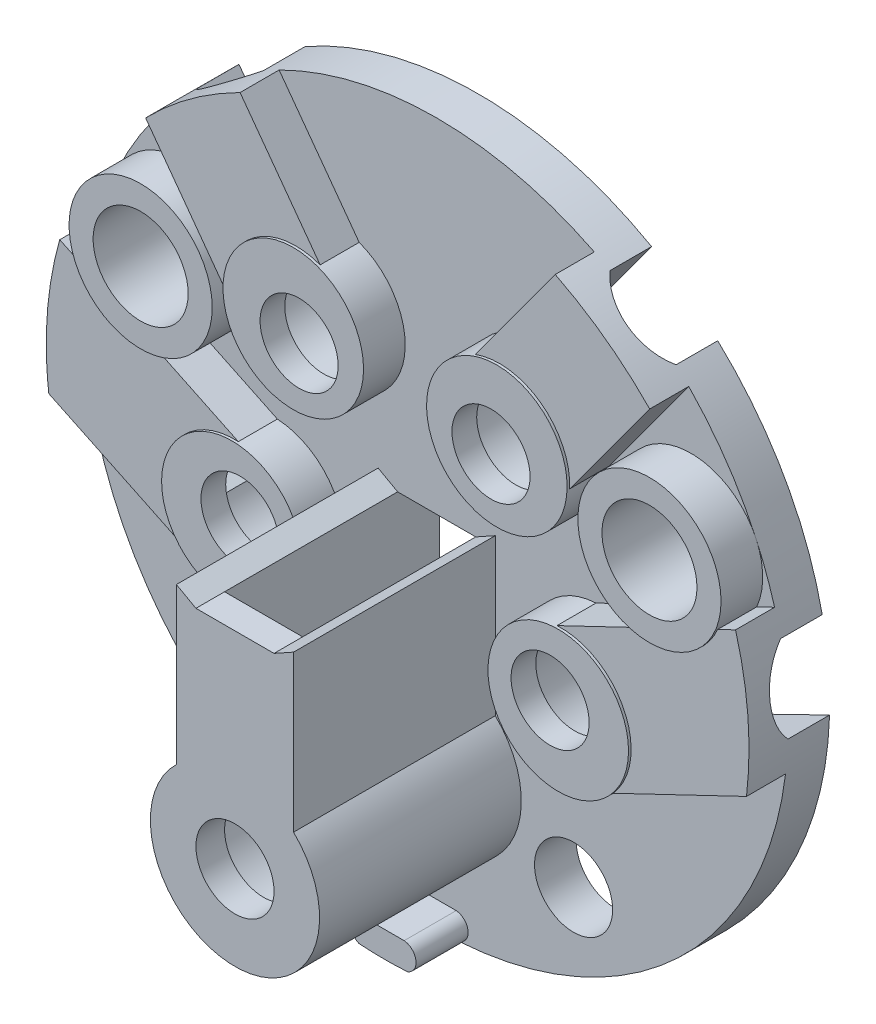
from build123d import *

# Parameters (mm, degrees)
SKETCH1_R           = 27
BOSS_EXTRUDE1_DEPTH = 3.2
BOSS_EXTRUDE2_DEPTH = 3
SKETCH2_4_R         = 5.4
SKETCH2_4_R_2       = 3
SKETCH2_4_R_3       = 3.65
BOSS_EXTRUDE3_DEPTH = 3.2
SKETCH2_5_R         = 3
BOSS_EXTRUDE4_DEPTH = 15.5
BOSS_EXTRUDE5_DEPTH = 4
SKETCH2_7_R         = 3.65
SKETCH2_7_R_2       = 3
CUT_EXTRUDE1_DEPTH  = 4.2
CUT_EXTRUDE2_DEPTH  = 3.2
SKETCH6_R           = 3
SKETCH6_R_2         = 4
CUT_EXTRUDE3_DEPTH  = 4.5
CUT_EXTRUDE4_START  = -14.26605
CUT_EXTRUDE4_DEPTH  = 14.26605
CUT_EXTRUDE5_START  = -11.120277
CUT_EXTRUDE5_DEPTH  = 11.304657
CUT_EXTRUDE6_DEPTH  = 16.5


with BuildPart() as part:
    # Sketch1 → Boss-Extrude1 (new body)
    with BuildSketch(Plane.XY):
        Circle(SKETCH1_R)
    extrude(amount=BOSS_EXTRUDE1_DEPTH)

    # Sketch2 → Boss-Extrude2 (add)
    with BuildSketch(Plane.XY.offset(3.2)):
        with BuildLine():
            Line((13.214734276, 10.418663089), (19.366760675, 18.812989687))
            ThreePointArc((19.366760675, 18.812989687), (15.960385268, 21.777651437), (12.10754353, 24.133118109))
            Line((12.10754353, 24.133118109), (5.95551713, 15.738791512))
            ThreePointArc((5.95551713, 15.738791512), (11.012715775, 15.026647634), (13.214734276, 10.418663089))
        make_face()
        with BuildLine():
            Line((-19.366760675, 18.812989687), (-13.214734276, 10.418663089))
            ThreePointArc((-13.214734276, 10.418663089), (-11.012715775, 15.026647634), (-5.95551713, 15.738791512))
            Line((-5.95551713, 15.738791512), (-12.10754353, 24.133118109))
            ThreePointArc((-12.10754353, 24.133118109), (-15.960385268, 21.777651437), (-19.366760675, 18.812989687))
        make_face()
        with BuildLine():
            Line((-26.803505249, -3.251477571), (-16.556347634, -8.162974501))
            ThreePointArc((-16.556347634, -8.162974501), (-17.408253142, -2.220860702), (-12.242617521, 0.837025499))
            Line((-12.242617521, 0.837025499), (-18.101719949, 3.645312897))
            ThreePointArc((-18.101719949, 3.645312897), (-21.924974658, 3.992090735), (-24.590072646, 6.755202054))
            Line((-24.590072646, 6.755202054), (-25.962429876, 7.412977466))
            ThreePointArc((-25.962429876, 7.412977466), (-26.916419296, 2.122821775), (-26.803505249, -3.251477571))
        make_face()
        with BuildLine():
            Line((16.556347634, -8.162974501), (26.803505249, -3.251477571))
            ThreePointArc((26.803505249, -3.251477571), (26.916419296, 2.122821775), (25.962429876, 7.412977466))
            Line((25.962429876, 7.412977466), (24.590072646, 6.755202054))
            ThreePointArc((24.590072646, 6.755202054), (21.924974658, 3.992090735), (18.101719949, 3.645312897))
            Line((18.101719949, 3.645312897), (12.242617521, 0.837025499))
            ThreePointArc((12.242617521, 0.837025499), (17.408253142, -2.220860702), (16.556347634, -8.162974501))
        make_face()
    extrude(amount=BOSS_EXTRUDE2_DEPTH)

    # Sketch2_4 → Boss-Extrude3 (add)
    with BuildSketch(Plane.XY.offset(3.2)):
        with Locations((-12.538705984, -4.554850949)):
            Circle(SKETCH2_4_R)
        with Locations((-11.912414596, -4.194547939)):
            Circle(SKETCH2_4_R_2, mode=Mode.SUBTRACT)
        with BuildLine():
            ThreePointArc((-24.590072646, 6.755202054), (-21.924974658, 3.992090735), (-18.101719949, 3.645312897))
            ThreePointArc((-18.101719949, 3.645312897), (-15.177222741, 5.612895206), (-14.047762371, 8.951814693))
            ThreePointArc((-14.047762371, 8.951814693), (-20.669656636, 14.336176611), (-24.590072646, 6.755202054))
        make_face()
        with Locations((-19.547762371, 8.951814693)):
            Circle(SKETCH2_4_R_3, mode=Mode.SUBTRACT)
        with Locations((-7.820638721, 10.671117346)):
            Circle(SKETCH2_4_R)
        with Locations((-7.372516546, 9.917200536)):
            Circle(SKETCH2_4_R_2, mode=Mode.SUBTRACT)
        with BuildLine():
            ThreePointArc((5.95551713, 15.738791512), (4.628561668, 6.315587059), (13.214734276, 10.418663089))
            ThreePointArc((13.214734276, 10.418663089), (13.219162408, 10.544855699), (13.220638721, 10.671117346))
            ThreePointArc((13.220638721, 10.671117346), (10.910003009, 15.100093334), (5.95551713, 15.738791512))
        make_face()
        with Locations((7.372516546, 9.917200536)):
            Circle(SKETCH2_4_R_2, mode=Mode.SUBTRACT)
        with BuildLine():
            ThreePointArc((25.047762371, 8.951814693), (16.208842883, 13.322354323), (18.101719949, 3.645312897))
            ThreePointArc((18.101719949, 3.645312897), (21.924974658, 3.992090735), (24.590072646, 6.755202054))
            ThreePointArc((24.590072646, 6.755202054), (24.932124288, 7.829920428), (25.047762371, 8.951814693))
        make_face()
        with Locations((19.547762371, 8.951814693)):
            Circle(SKETCH2_4_R_3, mode=Mode.SUBTRACT)
        with BuildLine():
            ThreePointArc((12.242617521, 0.837025499), (7.669158825, -6.888841195), (16.556347634, -8.162974501))
            ThreePointArc((16.556347634, -8.162974501), (17.581287907, -6.486784577), (17.938705984, -4.554850949))
            ThreePointArc((17.938705984, -4.554850949), (16.250923805, -0.633188183), (12.242617521, 0.837025499))
        make_face()
        with Locations((11.912414596, -4.194547939)):
            Circle(SKETCH2_4_R_2, mode=Mode.SUBTRACT)
    extrude(amount=BOSS_EXTRUDE3_DEPTH)

    # Sketch2_5 → Boss-Extrude4 (add)
    with BuildSketch(Plane.XY.offset(3.2)):
        with BuildLine():
            Line((-4.5, -10.531827265), (-4.5, 1.449233257))
            Line((-4.5, 1.449233257), (-3, 0.615924829))
            Line((-3, 0.615924829), (3, 0.615924829))
            Line((3, 0.615924829), (4.5, 1.449233257))
            Line((4.5, 1.449233257), (4.5, -10.531827265))
            ThreePointArc((4.5, -10.531827265), (0, -21.722243024), (-4.5, -10.531827265))
        make_face()
        with Locations((0, -15.222243024)):
            Circle(SKETCH2_5_R, mode=Mode.SUBTRACT)
    extrude(amount=BOSS_EXTRUDE4_DEPTH)

    # Sketch2_6 → Boss-Extrude5 (add)
    with BuildSketch(Plane.XY.offset(3.2)):
        with BuildLine():
            Line((-1.5, -25), (1.5, -25))
            ThreePointArc((1.5, -25), (2.404652846, -25.869777487), (1.75412196, -26.942959306))
            ThreePointArc((1.75412196, -26.942959306), (-0.110904579, -26.999772224), (-1.975401461, -26.927639872))
            ThreePointArc((-1.975401461, -26.927639872), (-2.565919795, -25.759561579), (-1.5, -25))
        make_face()
    extrude(amount=BOSS_EXTRUDE5_DEPTH)

    # Sketch2_7 → Cut-Extrude1 (cut, through all)
    with BuildSketch(Plane.XY.offset(3.2)):
        with Locations((-19.547762371, 8.951814693)):
            Circle(SKETCH2_7_R)
        with Locations((-11.912414596, -4.194547939)):
            Circle(SKETCH2_7_R_2)
        with Locations((-7.372516546, 9.917200536)):
            Circle(SKETCH2_7_R_2)
        with Locations((7.372516546, 9.917200536)):
            Circle(SKETCH2_7_R_2)
        with Locations((19.547762371, 8.951814693)):
            Circle(SKETCH2_7_R)
        with Locations((11.912414596, -4.194547939)):
            Circle(SKETCH2_7_R_2)
        with Locations((10.5168708, -18.935298149)):
            Circle(SKETCH2_7_R_2)
        with Locations((0, -15.222243024)):
            Circle(SKETCH2_7_R_2)
    extrude(amount=-CUT_EXTRUDE1_DEPTH, mode=Mode.SUBTRACT)

    # Sketch4 → Cut-Extrude2 (cut)
    with BuildSketch(Plane(origin=(0, 0, 0), x_dir=(-1, 0, 0), z_dir=(0, 0, -1))):
        with BuildLine():
            Line((6.737189652, 14.5215898), (15.050415108, 25.864832664))
            Line((15.050415108, 25.864832664), (20.13186711, 22.140742768))
            Line((20.13186711, 22.140742768), (11.818641654, 10.797499904))
            ThreePointArc((11.818641654, 10.797499904), (10.185140243, 13.897436078), (6.737189652, 14.5215898))
        make_face()
        with BuildLine():
            Line((13.60078494, -0.698429254), (28.388304519, 6.51769117))
            Line((28.388304519, 6.51769117), (31.019640476, 1.125467966))
            Line((31.019640476, 1.125467966), (16.232120898, -6.090652457))
            ThreePointArc((16.232120898, -6.090652457), (16.133521453, -2.800626977), (13.60078494, -0.698429254))
        make_face()
    cut_extrude2 = extrude(amount=-CUT_EXTRUDE2_DEPTH, mode=Mode.SUBTRACT)

    # Sketch6 → Cut-Extrude3 (cut)
    with BuildSketch(Plane(origin=(0, 0, 0), x_dir=(-1, 0, 0), z_dir=(0, 0, -1))):
        with BuildLine():
            ThreePointArc((16.232120898, -6.090652457), (16.461310964, -5.337902781), (16.538705984, -4.554850949))
            ThreePointArc((16.538705984, -4.554850949), (15.720554175, -2.130837317), (13.60078494, -0.698429254))
            ThreePointArc((13.60078494, -0.698429254), (8.943890515, -6.30907492), (16.232120898, -6.090652457))
        make_face()
        with Locations((11.912414596, -4.194547939)):
            Circle(SKETCH6_R, mode=Mode.SUBTRACT)
        with Locations((7.820638721, 10.671117346)):
            Circle(SKETCH6_R_2)
    cut_extrude3 = extrude(amount=-CUT_EXTRUDE3_DEPTH, mode=Mode.SUBTRACT)

    # Sketch12 → Cut-Extrude4 (cut)
    with BuildSketch(Plane(origin=(-23.530607991, 11.482635745, 26.182827122), x_dir=(0.192331359, 0.394131967, 0.898703867), z_dir=(-0.898703867, 0.438555993, 0)).offset(CUT_EXTRUDE4_START)):
        with BuildLine():
            Line((-26.177222318, -1.237570161), (-23.545886361, 4.154653043))
            ThreePointArc((-23.545886361, 4.154653043), (-23.693239312, 0.88841865), (-26.177222318, -1.237570161))
        make_face()
    cut_extrude4 = extrude(amount=CUT_EXTRUDE4_DEPTH, mode=Mode.SUBTRACT)

    # Sketch11 → Cut-Extrude5 (cut)
    with BuildSketch(Plane(origin=(-15.851393835, 21.628934636, 0), x_dir=(0.806579683, 0.59112538, 0), z_dir=(-0.59112538, 0.806579683, 0)).offset(CUT_EXTRUDE5_START)):
        with BuildLine():
            Line((-3.15, -3.2), (3.15, -3.2))
            ThreePointArc((3.15, -3.2), (0, -4.5), (-3.15, -3.2))
        make_face()
    cut_extrude5 = extrude(amount=CUT_EXTRUDE5_DEPTH, mode=Mode.SUBTRACT)

    # Mirror3: Cut-Extrude2, Cut-Extrude3, Cut-Extrude4 across plane
    add(cut_extrude2.mirror(Plane(origin=(0, 0, 0), x_dir=(0, 0, 1), z_dir=(1, 0, 0))), mode=Mode.SUBTRACT)
    add(cut_extrude3.mirror(Plane(origin=(0, 0, 0), x_dir=(0, 0, 1), z_dir=(1, 0, 0))), mode=Mode.SUBTRACT)
    add(cut_extrude4.mirror(Plane(origin=(0, 0, 0), x_dir=(0, 0, 1), z_dir=(1, 0, 0))), mode=Mode.SUBTRACT)

    # Mirror4: Cut-Extrude5 across plane
    add(cut_extrude5.mirror(Plane(origin=(0, 0, 0), x_dir=(0, 0, 1), z_dir=(1, 0, 0))), mode=Mode.SUBTRACT)

    # Sketch13 → Cut-Extrude6 (cut)
    with BuildSketch(Plane(origin=(0, 0, 0), x_dir=(-1, 0, 0), z_dir=(0, 0, -1))):
        with BuildLine():
            Line((-3, 0.615924829), (3, 0.615924829))
            Line((3, 0.615924829), (3, -11.539513059))
            ThreePointArc((3, -11.539513059), (0, -19.972243024), (-3, -11.539513059))
            Line((-3, -11.539513059), (-3, 0.615924829))
        make_face()
    extrude(amount=-CUT_EXTRUDE6_DEPTH, mode=Mode.SUBTRACT)


solid = part.part
